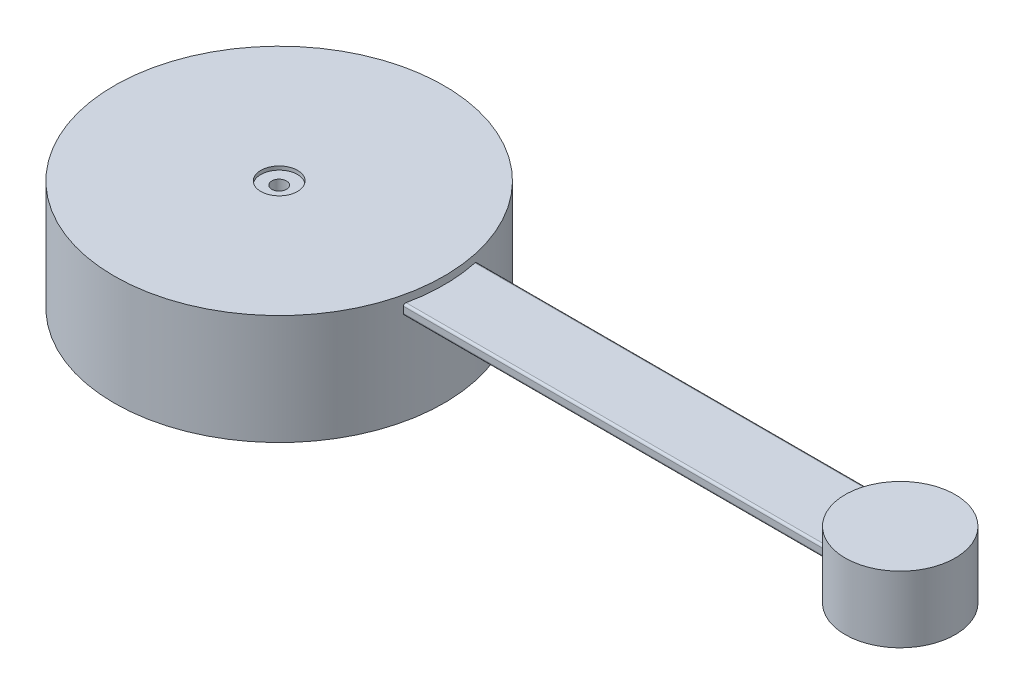
from build123d import *

# Parameters (mm, degrees)
SKETCH_1_R           = 22.5
EXTRUDE_1_DEPTH      = 7.5
SKETCH_3_R           = 7.5
EXTRUDE_2_DEPTH      = 7.5
SKETCH_4_W           = 23.480524837
SKETCH_4_H           = 9.129078989
CUT_EXTRUDE_2_DEPTH  = 97.083765538
EXTRUDE_3_REACH      = 113.978
EXTRUDE_3_END_RADIUS = 22.5
SKETCH_5_W           = 10
SKETCH_5_H           = 1.436694835
SKETCH_6_R           = 2.5
CUT_EXTRUDE_3_DEPTH  = 0.5
SKETCH_7_R           = 1
CUT_EXTRUDE_4_DEPTH  = 3
FILLET_1_R           = 0.3


with BuildPart() as part:
    # 草图1 → 凸台-拉伸1 (new, symmetric)
    with BuildSketch(Plane(origin=(0, 0, 0), x_dir=(1, 0, 0), z_dir=(0, 1, 0))):
        with Locations(Location((0, 0, 0), (0, 0, 270))):
            Circle(SKETCH_1_R)
    extrude(amount=EXTRUDE_1_DEPTH, both=True)



with BuildPart() as body_2:
    # 草图3 → 凸台-拉伸2 (new, symmetric)
    with BuildSketch(Plane(origin=(0, 7.5, 0), x_dir=(1, 0, 0), z_dir=(0, 1, 0))):
        with Locations(Location((84.7, 0, 0), (0, 0, 270))):
            Circle(SKETCH_3_R)
    extrude(amount=EXTRUDE_2_DEPTH, both=True)

    # 草图4 → 切除-拉伸2 (cut, through all)
    with BuildSketch(Plane(origin=(0, 0, 0), x_dir=(0, 0, -1), z_dir=(1, 0, 0))):
        with Locations((0.499792143, 13.617320583)):
            Rectangle(SKETCH_4_W, SKETCH_4_H)
    extrude(amount=CUT_EXTRUDE_2_DEPTH, mode=Mode.SUBTRACT)


with BuildPart() as part_1:
    add(part.part)

    add(body_2.part)  # 凸台-拉伸3 merges body 2
    # 凸台-拉伸3: up to this cylinder (the profile starts outside it)
    extrude_3_end = Plane(origin=(0, 5.748089, 0), z_dir=(0, -1, 0)) * Cylinder(EXTRUDE_3_END_RADIUS, 273.956, mode=Mode.PRIVATE)
    # 草图5 → 凸台-拉伸3 (add, up to the surface)
    with BuildSketch(Plane(origin=(86.82, 0, 0), x_dir=(0, 0, -1), z_dir=(1, 0, 0)), mode=Mode.PRIVATE) as extrude_3_sk1:
        with Locations((0, 5.748089048)):
            Rectangle(SKETCH_5_W, SKETCH_5_H)
    extrude_3_tool1 = extrude(extrude_3_sk1.sketch, amount=-EXTRUDE_3_REACH, mode=Mode.PRIVATE) - extrude_3_end
    add(extrude_3_tool1.solids().sort_by_distance((86.82, 5.748089, 0))[0])

    # 草图6 → 切除-拉伸3 (cut)
    with BuildSketch(Plane(origin=(0, 7.5, 0), x_dir=(1, 0, 0), z_dir=(0, 1, 0))):
        with Locations(Location((0, 0, 0), (0, 0, 270))):
            Circle(SKETCH_6_R)
    extrude(amount=-CUT_EXTRUDE_3_DEPTH, mode=Mode.SUBTRACT)

    # 草图7 → 切除-拉伸4 (cut)
    with BuildSketch(Plane(origin=(0, 7, 0), x_dir=(1, 0, 0), z_dir=(0, 1, 0))):
        with Locations(Location((0, 0, 0), (0, 0, 270))):
            Circle(SKETCH_7_R)
    extrude(amount=-CUT_EXTRUDE_4_DEPTH, mode=Mode.SUBTRACT)

    # 圆角1
    fillet_1_edges = [part_1.edges().sort_by_distance(p)[0] for p in [
        (50.523620512, 6.466436465, 5),
        (50.523620512, 5.02974163, -5),
        (50.523620512, 5.02974163, 5),
        (50.523620512, 6.466436465, -5),
    ]]
    fillet(fillet_1_edges, radius=FILLET_1_R)


solid = part_1.part
